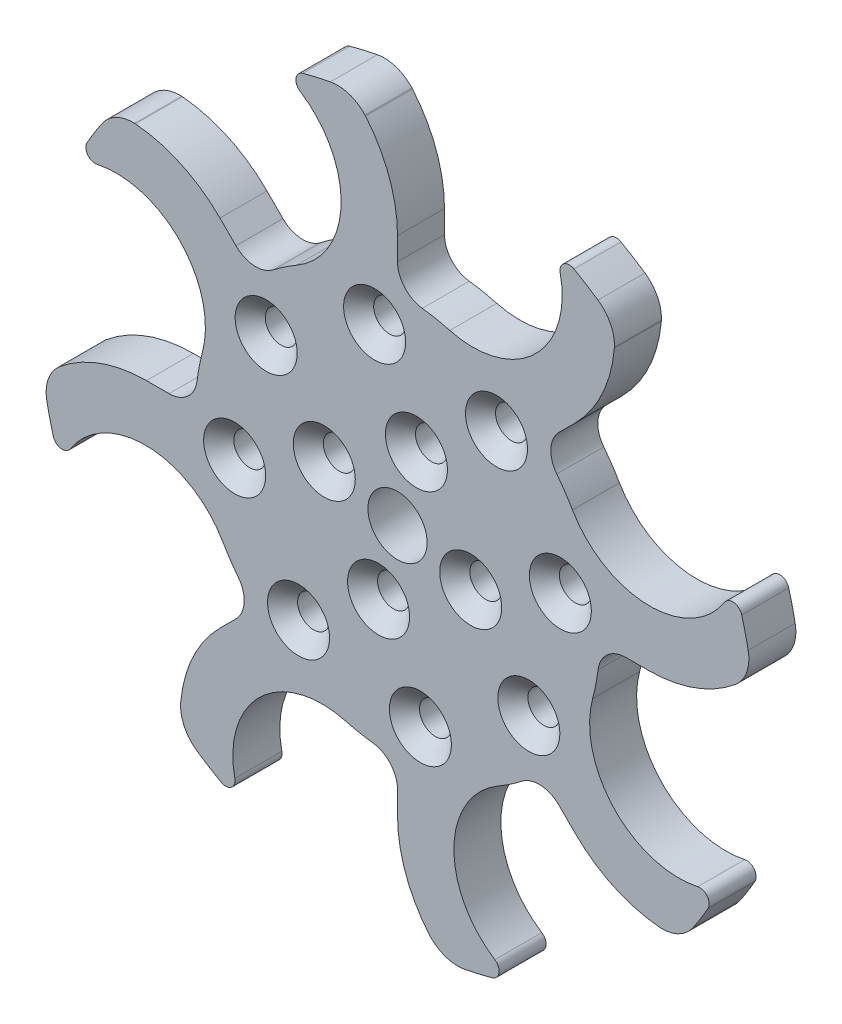
from build123d import *

# Parameters (mm, degrees)
EXTRUDE_1_DEPTH           = 5
PATTERN_CIRCULAR_1_COUNT  = 8
FILLET_1_R                = 3
SKETCH_4_R                = 1.6
SKETCH_4_R_2              = 1.65
SKETCH_4_R_3              = 3.15
CUT_EXTRUDE_2_DEPTH       = 5
HOLE_WIZARD_1_D           = 3.4
HOLE_WIZARD_1_CSINK_D     = 6.6
HOLE_WIZARD_1_CSINK_ANGLE = 90


with BuildPart() as part:
    # 草图1 → 凸台-拉伸1 (new body)
    with BuildSketch(Plane.XY):
        with BuildLine():
            ThreePointArc((-10.356244554, 34.83376316), (-6.00280003, 26.616152007), (-10.75, 18.619546181))
            ThreePointArc((-10.75, 18.619546181), (5.56460947, -20.767405265), (0, 21.5))
            Line((0, 21.5), (0, 26.721510215))
            ThreePointArc((0, 26.721510215), (-0.876562566, 31.680090761), (-3.4, 36.037629801))
            ThreePointArc((-3.4, 36.037629801), (-3.429921119, 36.072346995), (-3.460629906, 36.106369449))
            ThreePointArc((-3.460629906, 36.106369449), (-5.148861305, 37.192002716), (-7.15188578, 37.320912767))
            ThreePointArc((-7.15188578, 37.320912767), (-8.622723673, 37.00876432), (-10.080061386, 36.638673044))
            ThreePointArc((-10.080061386, 36.638673044), (-10.803291061, 35.82575459), (-10.356244554, 34.83376316))
        make_face()
    extrude_1 = extrude(amount=EXTRUDE_1_DEPTH)

    # 阵列(圆周)1: 凸台-拉伸1 ×8 about axis
    pattern_circular_1_axis = Axis((0, 0, 0), (0, 0, 1))
    for i in range(1, PATTERN_CIRCULAR_1_COUNT):
        add(extrude_1.rotate(pattern_circular_1_axis, i * 360 / PATTERN_CIRCULAR_1_COUNT))

    # 圆角1
    fillet_1_edges = [part.edges().sort_by_distance(p)[0] for p in [
        (0, 21.5, 2.5),
        (-15.202795796, 15.202795796, 2.5),
        (-15.202795796, -15.202795796, 2.5),
        (15.202795796, -15.202795796, 2.5),
        (15.202795796, 15.202795796, 2.5),
        (21.5, 0, 2.5),
        (0, -21.5, 2.5),
        (-21.5, 0, 2.5),
    ]]
    fillet(fillet_1_edges, radius=FILLET_1_R)

    # 草图4 → 切除-拉伸2 (cut)
    with BuildSketch(Plane.XY.offset(5)):
        with Locations((-2.435529267, 17.329691203)):
            Circle(SKETCH_4_R)
        with Locations((10.531762905, 13.976121426)):
            Circle(SKETCH_4_R)
        with Locations((17.329691203, 2.435529267)):
            Circle(SKETCH_4_R)
        with Locations((13.976121426, -10.531762905)):
            Circle(SKETCH_4_R)
        with Locations((2.435529267, -17.329691203)):
            Circle(SKETCH_4_R)
        with Locations((-10.531762905, -13.976121426)):
            Circle(SKETCH_4_R)
        with Locations((-17.329691203, -2.435529267)):
            Circle(SKETCH_4_R)
        with Locations((-13.976121426, 10.531762905)):
            Circle(SKETCH_4_R)
        with Locations((2.015559033, 7.793588505)):
            Circle(SKETCH_4_R_2)
        with Locations((7.793588505, -2.015559033)):
            Circle(SKETCH_4_R_2)
        with Locations((-2.015559033, -7.793588505)):
            Circle(SKETCH_4_R_2)
        with Locations((-7.793588505, 2.015559033)):
            Circle(SKETCH_4_R_2)
        Circle(SKETCH_4_R_3)
    extrude(amount=-CUT_EXTRUDE_2_DEPTH, mode=Mode.SUBTRACT)

    # 打孔尺寸(%根据十字)槽半沉头木螺钉的类型1 (through all)
    with Locations(Plane(origin=(-13.976121426, 10.531762905, 5), x_dir=(1, 0, 0), z_dir=(0, 0, 1))):
        with Locations((0, 0), (11.540592159, 6.797928298), (24.507884331, 3.444358521), (31.305812629, -8.096233638), (27.952242852, -21.06352581), (16.411650693, -27.861454108), (3.444358521, -24.507884331), (-3.353569777, -12.967292172), (6.182532921, -8.516203872), (15.991680459, -2.7381744), (21.769709931, -12.547321938), (11.960562393, -18.32535141)):
            CounterSinkHole(HOLE_WIZARD_1_D / 2, HOLE_WIZARD_1_CSINK_D / 2, counter_sink_angle=HOLE_WIZARD_1_CSINK_ANGLE)


solid = part.part
